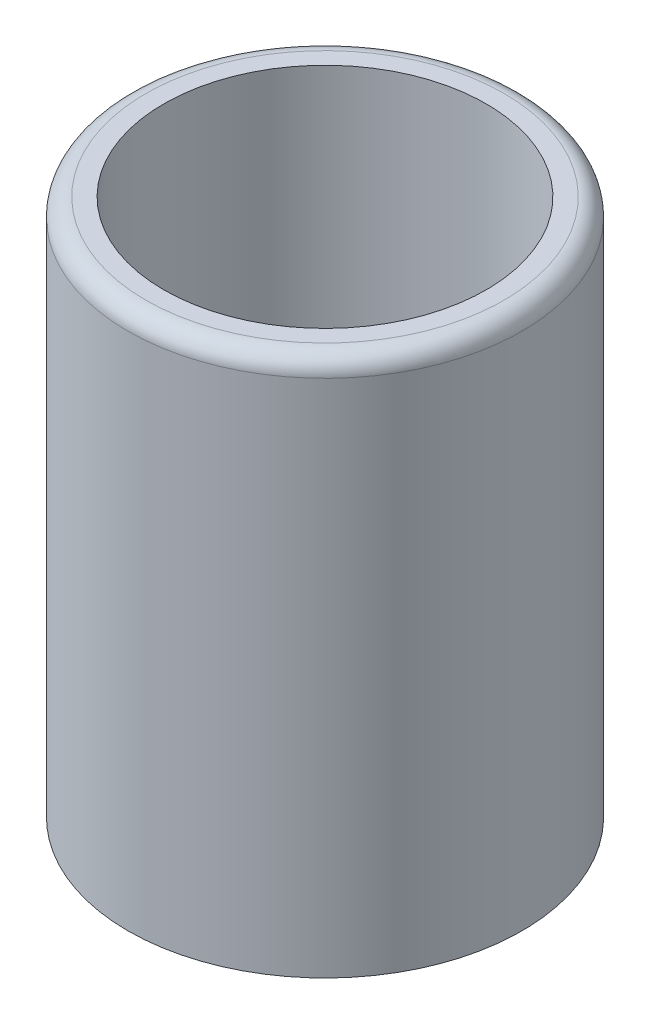
from build123d import *

# Parameters (mm, degrees)
ESBO_O1_R                = 11
RESSALTO_EXTRUS_O1_DEPTH = 30
CASCA1_T                 = -2
FILETE1_R                = 1


with BuildPart() as part:
    # Esboço1 → Ressalto-extrusão1 (new body)
    with BuildSketch(Plane(origin=(0, 0, 0), x_dir=(1, 0, 0), z_dir=(0, 1, 0))):
        with Locations(Location((0, 0, 0), (0, 0, 270))):  # turned: the seam where the file's is
            Circle(ESBO_O1_R)
    extrude(amount=RESSALTO_EXTRUS_O1_DEPTH)

    # Casca1
    casca1_openings = [part.faces().sort_by_distance(p)[0] for p in [
        (0, 30, 0),
    ]]
    offset(amount=CASCA1_T, openings=casca1_openings, kind=Kind.INTERSECTION)

    # Filete1
    filete1_edges = [part.edges().sort_by_distance(p)[0] for p in [
        (0, 30, -11),
    ]]
    fillet(filete1_edges, radius=FILETE1_R)


solid = part.part
